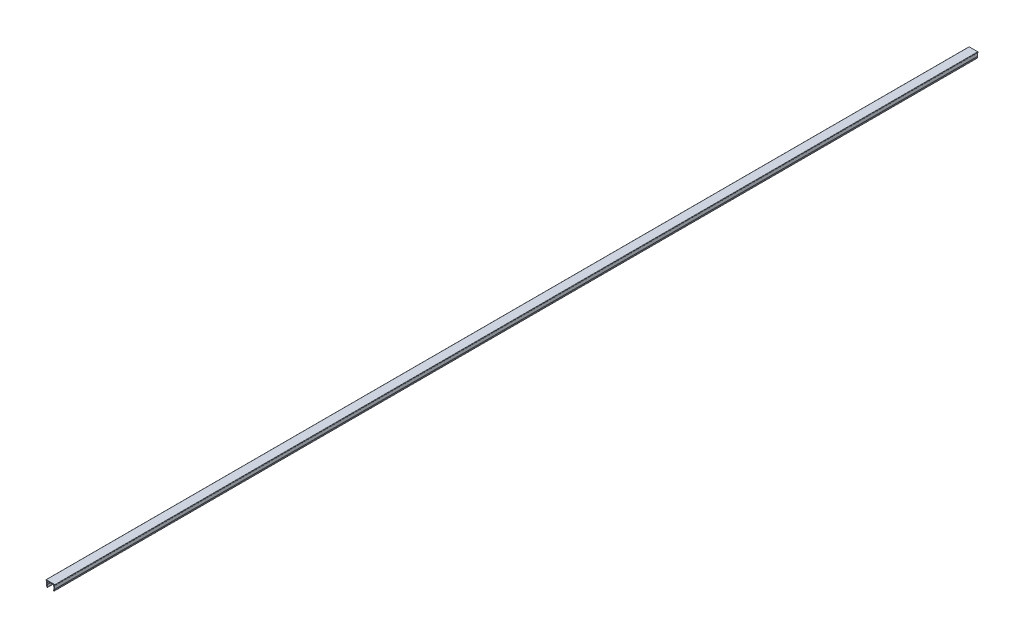
from build123d import *

# Parameters (mm, degrees)
EXTRUDE_1_DEPTH = 1000


with BuildPart() as part:
    # 草图1 → 拉伸1 (new body)
    with BuildSketch(Plane.XY):
        with BuildLine():
            Line((9.957625481, 89.483322587), (10.600277657, 91.248994929))
            ThreePointArc((10.600277657, 91.248994929), (10.620053384, 91.338197469), (10.616067953, 91.429478841))
            Line((10.616067953, 91.429478841), (10.013039731, 94.849421835))
            Line((10.013039731, 94.849421835), (3.609954409, 94.849421835))
            Line((3.609954409, 94.849421835), (3.007969074, 91.435393352))
            ThreePointArc((3.007969074, 91.435393352), (3.003983643, 91.34411198), (3.02375937, 91.25490944))
            Line((3.02375937, 91.25490944), (3.665329884, 89.49220894))
            ThreePointArc((3.665329884, 89.49220894), (3.426260893, 88.979523834), (2.913575787, 89.218592825))
            Line((2.913575787, 89.218592825), (2.25631362, 91.024405789))
            ThreePointArc((2.25631362, 91.024405789), (2.199811543, 91.27927019), (2.211198488, 91.54007411))
            Line((2.211198488, 91.54007411), (2.79472578, 94.849421835))
            Line((2.79472578, 94.849421835), (2.11149707, 94.849421835))
            ThreePointArc((2.11149707, 94.849421835), (1.970075714, 94.908000479), (1.91149707, 95.049421835))
            Line((1.91149707, 95.049421835), (1.91149707, 95.349421835))
            ThreePointArc((1.91149707, 95.349421835), (1.999365035, 95.56155387), (2.21149707, 95.649421835))
            Line((2.21149707, 95.649421835), (11.41149707, 95.649421835))
            ThreePointArc((11.41149707, 95.649421835), (11.623629104, 95.56155387), (11.71149707, 95.349421835))
            Line((11.71149707, 95.349421835), (11.71149707, 95.049421835))
            ThreePointArc((11.71149707, 95.049421835), (11.652918426, 94.908000479), (11.51149707, 94.849421835))
            Line((11.51149707, 94.849421835), (10.826662681, 94.849421835))
            Line((10.826662681, 94.849421835), (11.411756877, 91.531187757))
            ThreePointArc((11.411756877, 91.531187757), (11.423143822, 91.270383837), (11.366641745, 91.015519436))
            Line((11.366641745, 91.015519436), (10.709379578, 89.209706473))
            ThreePointArc((10.709379578, 89.209706473), (10.196694472, 88.970637482), (9.957625481, 89.483322587))
        make_face()
    extrude(amount=EXTRUDE_1_DEPTH)


solid = part.part
